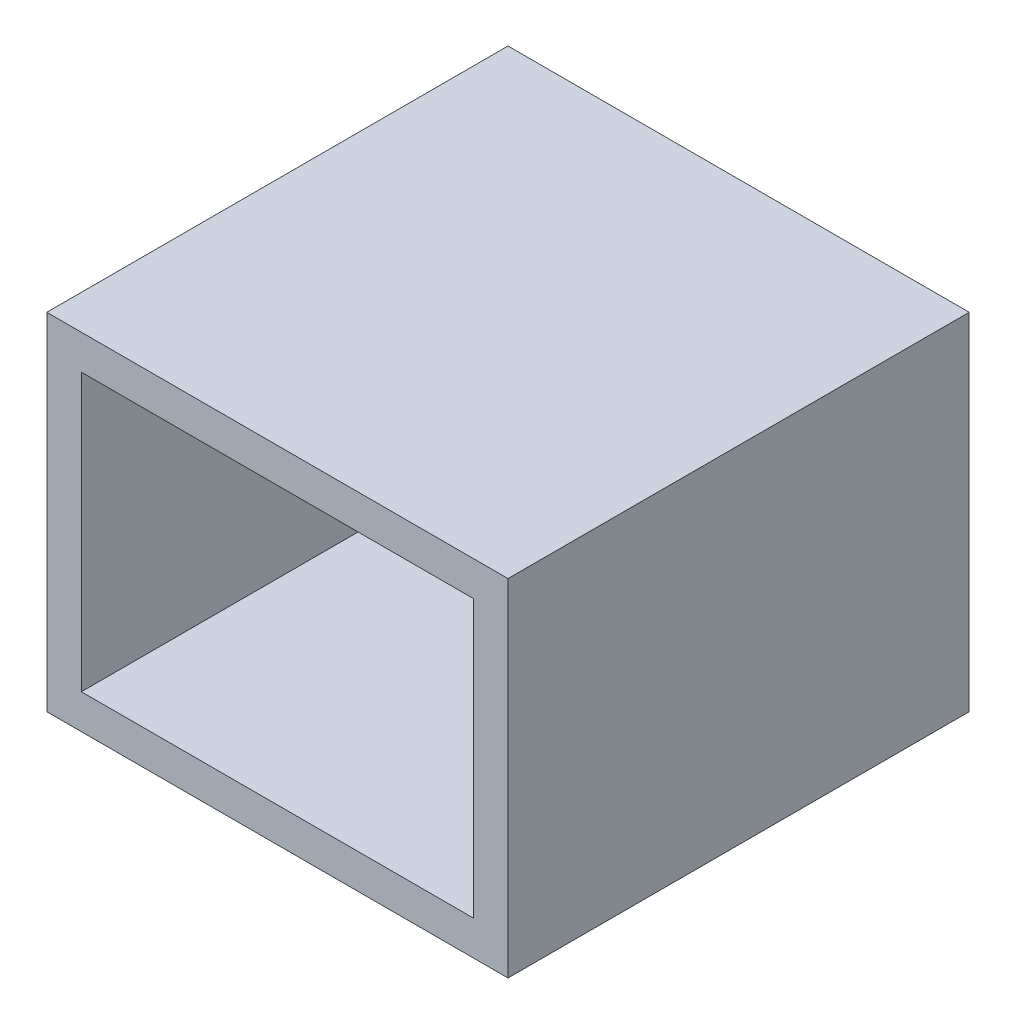
from build123d import *

# Parameters (mm, degrees)
SKETCH_1_W          = 40
SKETCH_1_H          = 30
EXTRUDE_1_DEPTH     = 40
SKETCH_2_W          = 34
SKETCH_2_H          = 24
CUT_EXTRUDE_1_DEPTH = 37


with BuildPart() as part:
    # 草图1 → 凸台-拉伸1 (new body)
    with BuildSketch(Plane.XY):
        with Locations((6.330275229, 16.314220183)):
            Rectangle(SKETCH_1_W, SKETCH_1_H)
    extrude(amount=EXTRUDE_1_DEPTH)

    # 草图2 → 切除-拉伸1 (cut)
    with BuildSketch(Plane.XY.offset(40)):
        with Locations((6.330275229, 16.314220183)):
            Rectangle(SKETCH_2_W, SKETCH_2_H)
    extrude(amount=-CUT_EXTRUDE_1_DEPTH, mode=Mode.SUBTRACT)


solid = part.part
